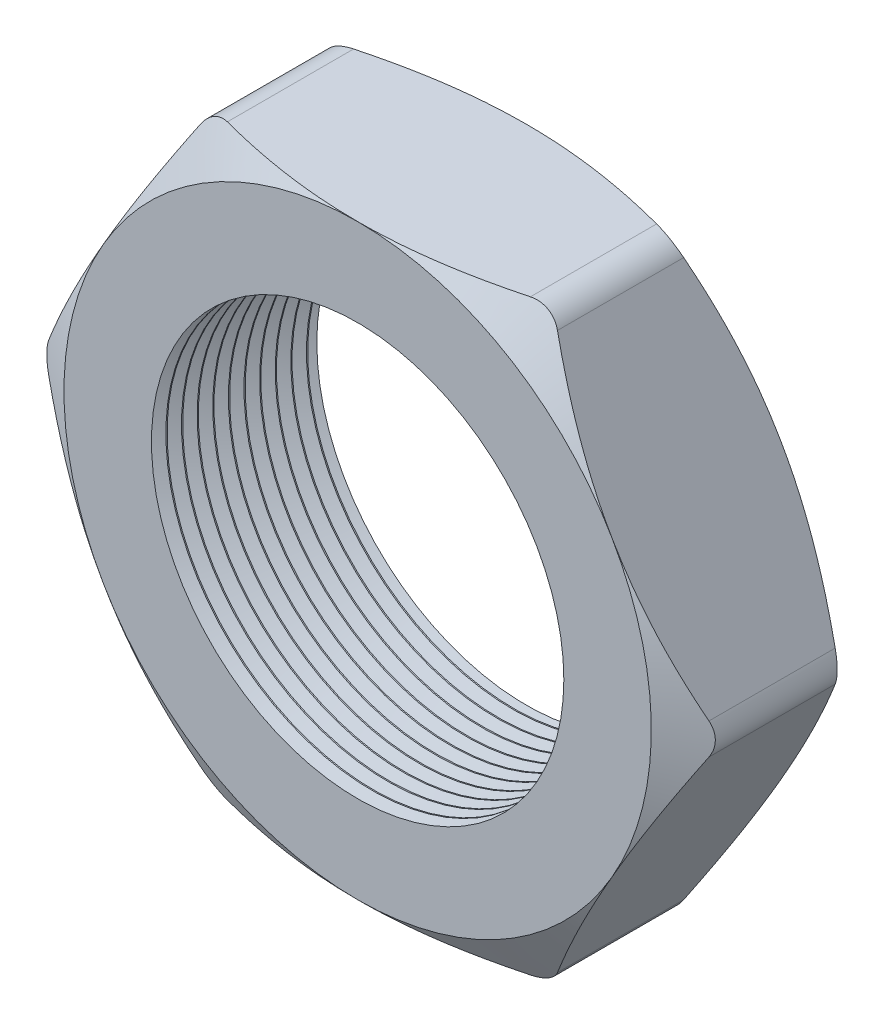
from build123d import *

# Parameters (mm, degrees)
SKETCH1_R          = 8.382
EXTRUDE1_DEPTH     = 6.858
SKETCH2_OUTSIDE_W  = 64.212
SKETCH2_OUTSIDE_H  = 60.518
SKETCH2_OUTSIDE_R  = 11.938
CUT_EXTRUDE1_DEPTH = 7.858
CUT_EXTRUDE1_DRAFT = -60
SKETCH3_OUTSIDE_W  = 64.212
SKETCH3_OUTSIDE_H  = 60.518
SKETCH3_OUTSIDE_R  = 11.938
CUT_EXTRUDE2_DEPTH = 7.858
CUT_EXTRUDE2_DRAFT = -60
FILLET1_R          = 1.27
LPATTERN1_COUNT    = 11
LPATTERN1_PITCH    = 0.635


with BuildPart() as part:
    # Sketch1 → Extrude1 (new body)
    with BuildSketch(Plane.XY):
        Polygon((-13.784815027, 0), (-6.892407514, -11.938), (6.892407514, -11.938), (13.784815027, 0), (6.892407514, 11.938), (-6.892407514, 11.938), align=None)
        Circle(SKETCH1_R, mode=Mode.SUBTRACT)
    extrude(amount=EXTRUDE1_DEPTH)


with BuildPart() as cut_extrude1_tool:
    # Sketch2 outside → Cut-Extrude1 (with draft: the straight prism first)
    with BuildSketch(Plane.XY.offset(6.858)):
        Rectangle(SKETCH2_OUTSIDE_W, SKETCH2_OUTSIDE_H)
        Circle(SKETCH2_OUTSIDE_R, mode=Mode.SUBTRACT)
    extrude(amount=-CUT_EXTRUDE1_DEPTH)
    # Cut-Extrude1: the draft: its side faces are tilted about the plane it starts from
    cut_extrude1_sides = [cut_extrude1_tool.faces().sort_by_distance(p)[0] for p in [
        (0, -30.259, 2.929),
        (32.106, 0, 2.929),
        (0, 30.259, 2.929),
        (-32.106, 0, 2.929),
        (-11.938, 0, 2.929),
    ]]
    draft(cut_extrude1_sides, Plane.XY.offset(6.858), CUT_EXTRUDE1_DRAFT)


with BuildPart() as part_1:
    add(part.part)

    # Cut-Extrude1: cut by cut_extrude1_tool
    add(cut_extrude1_tool.part, mode=Mode.SUBTRACT)


with BuildPart() as cut_extrude2_tool:
    # Sketch3 outside → Cut-Extrude2 (with draft: the straight prism first)
    with BuildSketch(Plane(origin=(0, 0, 0), x_dir=(-1, 0, 0), z_dir=(0, 0, -1))):
        Rectangle(SKETCH3_OUTSIDE_W, SKETCH3_OUTSIDE_H)
        Circle(SKETCH3_OUTSIDE_R, mode=Mode.SUBTRACT)
    extrude(amount=-CUT_EXTRUDE2_DEPTH)
    # Cut-Extrude2: the draft: its side faces are tilted about the plane it starts from
    cut_extrude2_sides = [cut_extrude2_tool.faces().sort_by_distance(p)[0] for p in [
        (0, -30.259, 3.929),
        (-32.106, 0, 3.929),
        (0, 30.259, 3.929),
        (32.106, 0, 3.929),
        (11.938, 0, 3.929),
    ]]
    draft(cut_extrude2_sides, Plane(origin=(0, 0, 0), x_dir=(-1, 0, 0), z_dir=(0, 0, -1)), CUT_EXTRUDE2_DRAFT)


with BuildPart() as part_2:
    add(part_1.part)

    # Cut-Extrude2: cut by cut_extrude2_tool
    add(cut_extrude2_tool.part, mode=Mode.SUBTRACT)

    # Fillet1
    fillet1_edges = [part_2.edges().sort_by_distance(p)[0] for p in [
        (13.784815027, 0, 3.429),
        (6.892407514, -11.938, 3.429),
        (-6.892407514, -11.938, 3.429),
        (-13.784815027, 0, 3.429),
        (-6.892407514, 11.938, 3.429),
        (6.892407514, 11.938, 3.429),
    ]]
    fillet(fillet1_edges, radius=FILLET1_R)

    # Sketch4 → Cut-Revolve1 (revolve, cut)
    with BuildSketch(Plane(origin=(0, 0, 0), x_dir=(1, 0, 0), z_dir=(0, 1, 0)), mode=Mode.PRIVATE) as cut_revolve1_sk:
        Polygon((-8.382, -6.858), (-8.382, -6.271412127), (-8.89, -6.564706063), align=None)
    cut_revolve1 = revolve(cut_revolve1_sk.sketch.rotate(Axis((0, 0, 0), (0, 0, 1)), 180), axis=Axis((0, 0, 0), (0, 0, 1)), mode=Mode.SUBTRACT)  # turned: the seam where the file's is

    # LPattern1: Cut-Revolve1 ×11
    with Locations(*[(0, 0, -i * LPATTERN1_PITCH) for i in range(1, LPATTERN1_COUNT)]):
        add(cut_revolve1, mode=Mode.SUBTRACT)


solid = part_2.part
